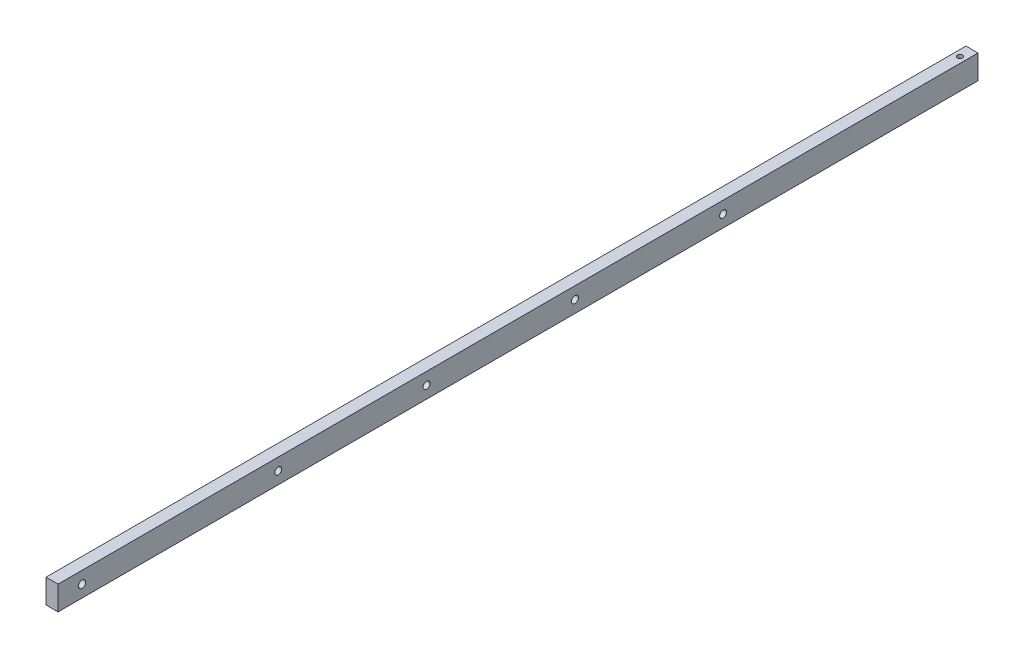
from build123d import *

# Parameters (mm, degrees)
SKETCH1_W                 = 6.35
SKETCH1_H                 = 12.7
BOSS_EXTRUDE1_DEPTH       = 485.14
F_6_CLEARANCE_HOLE1_D     = 3.7973
TAP_DRILL_FOR_6_32_TAP1_D = 2.7051
F_6_CLEARANCE_HOLE2_D     = 3.6576


with BuildPart() as part:
    # Sketch1 → Boss-Extrude1 (new body)
    with BuildSketch(Plane.XY):
        with Locations((3.175, 6.35)):
            Rectangle(SKETCH1_W, SKETCH1_H)
    extrude(amount=BOSS_EXTRUDE1_DEPTH)

    # #6 Clearance Hole1 (through all)
    with Locations(Plane(origin=(6.35, 0, 0), x_dir=(0, 0, -1), z_dir=(1, 0, 0))):
        with Locations((-472.44, 6.35)):
            Hole(F_6_CLEARANCE_HOLE1_D / 2)

    # Tap Drill for #6-32 Tap1 (through all)
    with Locations(Plane(origin=(0, 12.7, 0), x_dir=(1, 0, 0), z_dir=(0, 1, 0))):
        with Locations((3.175, -6.35)):
            Hole(TAP_DRILL_FOR_6_32_TAP1_D / 2)

    # #6 Clearance Hole2 (through all)
    with Locations(Plane(origin=(0, 1342.118435602, -1739.809386822), x_dir=(0, 0, -1), z_dir=(-1, 0, 0))):
        with Locations((-2108.842826276, 1335.768435602), (-1952.378826276, 1335.768435602), (-2030.610826276, 1335.768435602), (-1874.240025135, 1335.768435602)):
            Hole(F_6_CLEARANCE_HOLE2_D / 2)


solid = part.part
